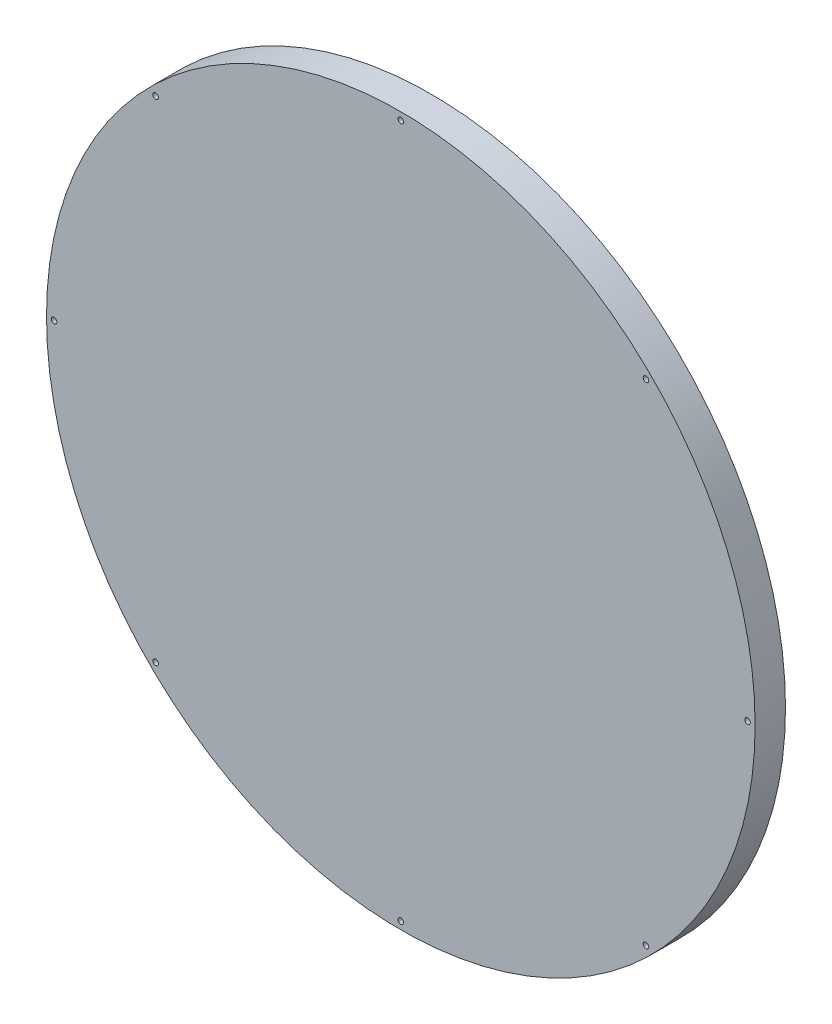
from build123d import *

# Parameters (mm, degrees)
SKETCH1_R                                       = 140
BOSS_EXTRUDE1_DEPTH                             = 12
CSK_FOR_M2_FLAT_HEAD_MACHINE_SCREW1_D           = 2.2
CSK_FOR_M2_FLAT_HEAD_MACHINE_SCREW1_CSINK_D     = 4.4
CSK_FOR_M2_FLAT_HEAD_MACHINE_SCREW1_CSINK_ANGLE = 90


with BuildPart() as part:
    # Sketch1 → Boss-Extrude1 (new body)
    with BuildSketch(Plane.XY):
        Circle(SKETCH1_R)
    extrude(amount=BOSS_EXTRUDE1_DEPTH)

    # CSK for M2 Flat Head Machine Screw1 (through all)
    with Locations(Plane(origin=(0, 0, 0), x_dir=(-1, 0, 0), z_dir=(0, 0, -1))):
        with Locations((0, 137), (137, 0), (0, -137), (-137, 0), (-96.874, 96.874), (96.874, 96.874), (96.874, -96.874), (-96.874, -96.874)):
            CounterSinkHole(CSK_FOR_M2_FLAT_HEAD_MACHINE_SCREW1_D / 2, CSK_FOR_M2_FLAT_HEAD_MACHINE_SCREW1_CSINK_D / 2, counter_sink_angle=CSK_FOR_M2_FLAT_HEAD_MACHINE_SCREW1_CSINK_ANGLE)


solid = part.part
